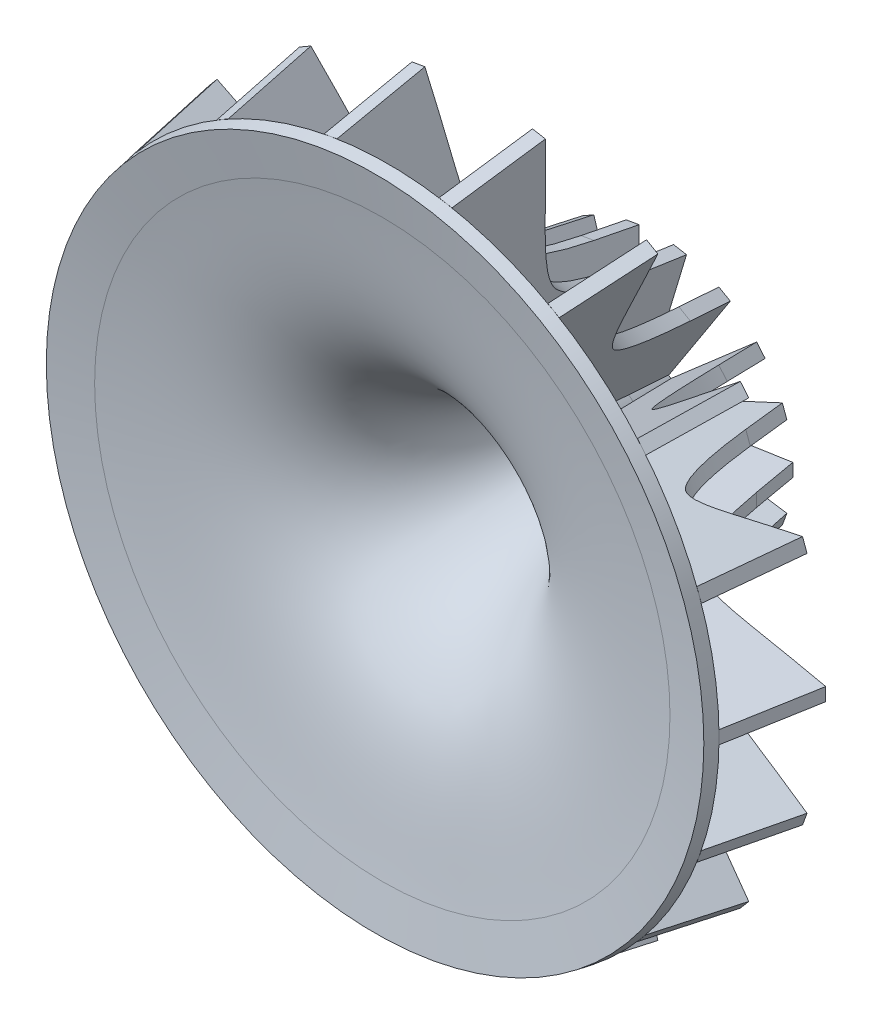
from build123d import *

# Parameters (mm, degrees)
BLADE_DEPTH         = 0.5
BLADE_PATTERN_COUNT = 18


with BuildPart() as part:
    # Sketch_of_Hub → Hub (revolve)
    with BuildSketch(Plane(origin=(0, 0, 0), x_dir=(1, 0, 0), z_dir=(0, 1, 0))):
        with BuildLine():
            Line((-25, 0), (-21.875, 0.551021815))
            add(Edge.make_bspline(
                [(-21.875, 0.551021815), (-12.655262266, 2.176710332), (-5.675135971, 1.992909092), (-3.087756602, 16.666666667)],
                knots=[0, 0, 0, 0, 1, 1, 1, 1], degree=3))
            Line((-3.087756602, 16.666666667), (-2.5, 20))
            Line((-2.5, 20), (-3.484807753, 20.173648178))
            Line((-3.484807753, 20.173648178), (-4.072564355, 16.840314844))
            add(Edge.make_bspline(
                [(-22.048648178, 1.535829568), (-21.478094224, 1.636433624), (-20.317964448, 1.829846586), (-18.133137488, 2.182078373), (-15.573097923, 2.634890711), (-12.841426017, 3.375790026), (-10.465375823, 4.478355969), (-8.417885764, 6.109004535), (-6.938701311, 8.105088767), (-5.897979088, 10.21708179), (-5.196580182, 12.084345826), (-4.682308699, 13.905719087), (-4.319333433, 15.516895238), (-4.149347465, 16.40485619), (-4.072564355, 16.840314844)],
                knots=[0, 0, 0, 0, 0.0625, 0.125, 0.25, 0.375, 0.5, 0.625, 0.75, 0.8125, 0.875, 0.9375, 0.96875, 1, 1, 1, 1], degree=3))
            Line((-22.048648178, 1.535829568), (-25.173648178, 0.984807753))
            Line((-25.173648178, 0.984807753), (-25, 0))
        make_face()
    revolve(axis=Axis((0, 0, 11.410665709), (0, 0, -1)))


with BuildPart() as body_2:
    # Sketch9 → Blade (new body, symmetric)
    with BuildSketch(Plane(origin=(0, 0, 0), x_dir=(1, 0, 0), z_dir=(0, 1, 0))):
        with BuildLine():
            Line((-10.378462024, 21.389185421), (-10.966218626, 18.055852088))
            add(Edge.make_bspline(
                [(-10.966218626, 18.055852088), (-11.030806768, 17.689554534), (-11.175810218, 16.93293623), (-11.468615135, 15.635689405), (-11.866926993, 14.233267736), (-12.34667485, 12.968667896), (-12.959130247, 11.742656166), (-13.569357152, 10.977560712), (-14.123332094, 10.531724998), (-15.134839985, 10.023561208), (-16.688956317, 9.584048646), (-18.359611032, 9.25142554), (-19.810816671, 9.001980231), (-21.428121028, 8.741362776), (-22.666214106, 8.534922315), (-23.264185421, 8.429483839)],
                knots=[0, 0, 0, 0, 0.03125, 0.0625, 0.125, 0.1875, 0.25, 0.375, 0.5, 0.625, 0.75, 0.8125, 0.875, 0.9375, 1, 1, 1, 1], degree=3))
            Line((-23.264185421, 8.429483839), (-26.389185421, 7.878462024))
            Line((-26.389185421, 7.878462024), (-25.173648178, 0.984807753))
            Line((-25.173648178, 0.984807753), (-22.048648178, 1.535829568))
            add(Edge.make_bspline(
                [(-4.072564355, 16.840314844), (-4.149347465, 16.40485619), (-4.319333433, 15.516895238), (-4.682308699, 13.905719087), (-5.196580182, 12.084345826), (-5.897979088, 10.21708179), (-6.938701311, 8.105088767), (-8.417885764, 6.109004535), (-10.465375823, 4.478355969), (-12.841426017, 3.375790026), (-15.573097923, 2.634890711), (-18.133137488, 2.182078373), (-20.317964448, 1.829846586), (-21.478094224, 1.636433624), (-22.048648178, 1.535829568)],
                knots=[0, 0, 0, 0, 0.03125, 0.0625, 0.125, 0.1875, 0.25, 0.375, 0.5, 0.625, 0.75, 0.875, 0.9375, 1, 1, 1, 1], degree=3))
            Line((-4.072564355, 16.840314844), (-3.484807753, 20.173648178))
            Line((-3.484807753, 20.173648178), (-10.378462024, 21.389185421))
        make_face()
    extrude(amount=BLADE_DEPTH, both=True)


with BuildPart() as blade_pattern_1:
    # Blade_Pattern: pattern copy
    add(body_2.part.rotate(Axis((0, 0, -20.173648178), (0, 0, 1)), 1 * 360 / BLADE_PATTERN_COUNT))


with BuildPart() as blade_pattern_2:
    # Blade_Pattern: pattern copy
    add(body_2.part.rotate(Axis((0, 0, -20.173648178), (0, 0, 1)), 2 * 360 / BLADE_PATTERN_COUNT))


with BuildPart() as blade_pattern_3:
    # Blade_Pattern: pattern copy
    add(body_2.part.rotate(Axis((0, 0, -20.173648178), (0, 0, 1)), 3 * 360 / BLADE_PATTERN_COUNT))


with BuildPart() as blade_pattern_4:
    # Blade_Pattern: pattern copy
    add(body_2.part.rotate(Axis((0, 0, -20.173648178), (0, 0, 1)), 4 * 360 / BLADE_PATTERN_COUNT))


with BuildPart() as blade_pattern_5:
    # Blade_Pattern: pattern copy
    add(body_2.part.rotate(Axis((0, 0, -20.173648178), (0, 0, 1)), 5 * 360 / BLADE_PATTERN_COUNT))


with BuildPart() as blade_pattern_6:
    # Blade_Pattern: pattern copy
    add(body_2.part.rotate(Axis((0, 0, -20.173648178), (0, 0, 1)), 6 * 360 / BLADE_PATTERN_COUNT))


with BuildPart() as blade_pattern_7:
    # Blade_Pattern: pattern copy
    add(body_2.part.rotate(Axis((0, 0, -20.173648178), (0, 0, 1)), 7 * 360 / BLADE_PATTERN_COUNT))


with BuildPart() as blade_pattern_8:
    # Blade_Pattern: pattern copy
    add(body_2.part.rotate(Axis((0, 0, -20.173648178), (0, 0, 1)), 8 * 360 / BLADE_PATTERN_COUNT))


with BuildPart() as blade_pattern_9:
    # Blade_Pattern: pattern copy
    add(body_2.part.rotate(Axis((0, 0, -20.173648178), (0, 0, 1)), 9 * 360 / BLADE_PATTERN_COUNT))


with BuildPart() as blade_pattern_10:
    # Blade_Pattern: pattern copy
    add(body_2.part.rotate(Axis((0, 0, -20.173648178), (0, 0, 1)), 10 * 360 / BLADE_PATTERN_COUNT))


with BuildPart() as blade_pattern_11:
    # Blade_Pattern: pattern copy
    add(body_2.part.rotate(Axis((0, 0, -20.173648178), (0, 0, 1)), 11 * 360 / BLADE_PATTERN_COUNT))


with BuildPart() as blade_pattern_12:
    # Blade_Pattern: pattern copy
    add(body_2.part.rotate(Axis((0, 0, -20.173648178), (0, 0, 1)), 12 * 360 / BLADE_PATTERN_COUNT))


with BuildPart() as blade_pattern_13:
    # Blade_Pattern: pattern copy
    add(body_2.part.rotate(Axis((0, 0, -20.173648178), (0, 0, 1)), 13 * 360 / BLADE_PATTERN_COUNT))


with BuildPart() as blade_pattern_14:
    # Blade_Pattern: pattern copy
    add(body_2.part.rotate(Axis((0, 0, -20.173648178), (0, 0, 1)), 14 * 360 / BLADE_PATTERN_COUNT))


with BuildPart() as blade_pattern_15:
    # Blade_Pattern: pattern copy
    add(body_2.part.rotate(Axis((0, 0, -20.173648178), (0, 0, 1)), 15 * 360 / BLADE_PATTERN_COUNT))


with BuildPart() as blade_pattern_16:
    # Blade_Pattern: pattern copy
    add(body_2.part.rotate(Axis((0, 0, -20.173648178), (0, 0, 1)), 16 * 360 / BLADE_PATTERN_COUNT))


with BuildPart() as blade_pattern_17:
    # Blade_Pattern: pattern copy
    add(body_2.part.rotate(Axis((0, 0, -20.173648178), (0, 0, 1)), 17 * 360 / BLADE_PATTERN_COUNT))


solid = Compound([part.part, body_2.part, blade_pattern_1.part, blade_pattern_2.part, blade_pattern_3.part, blade_pattern_4.part, blade_pattern_5.part, blade_pattern_6.part, blade_pattern_7.part, blade_pattern_8.part, blade_pattern_9.part, blade_pattern_10.part, blade_pattern_11.part, blade_pattern_12.part, blade_pattern_13.part, blade_pattern_14.part, blade_pattern_15.part, blade_pattern_16.part, blade_pattern_17.part])
